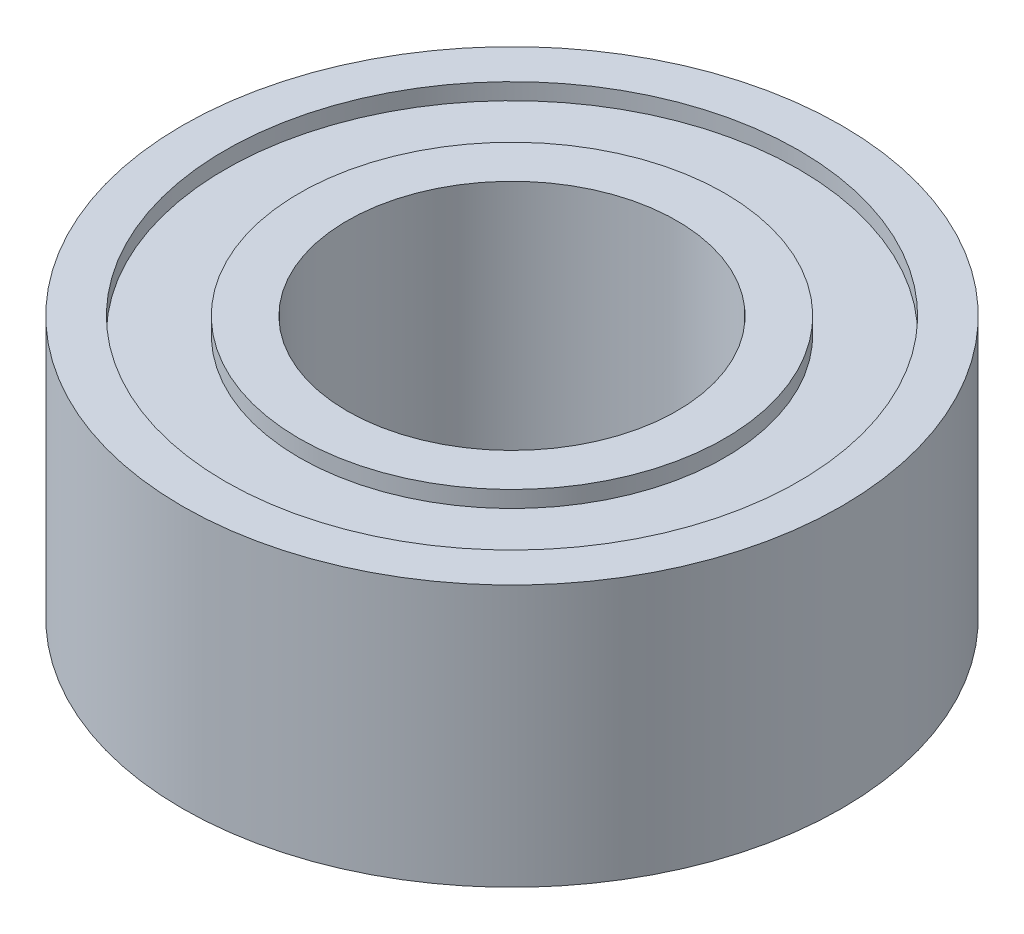
from build123d import *

# Parameters (mm, degrees)
SKETCH1_R           = 5
SKETCH1_R_2         = 2.5
BOSS_EXTRUDE1_DEPTH = 3.97
SKETCH2_R           = 4.35
SKETCH2_R_2         = 3.225
CUT_EXTRUDE1_DEPTH  = 0.25
SKETCH3_R           = 4.35
SKETCH3_R_2         = 3.225
CUT_EXTRUDE2_DEPTH  = 0.25


with BuildPart() as part:
    # Sketch1 → Boss-Extrude1 (new body)
    with BuildSketch(Plane(origin=(0, 0, 0), x_dir=(1, 0, 0), z_dir=(0, 1, 0))):
        Circle(SKETCH1_R)
        Circle(SKETCH1_R_2, mode=Mode.SUBTRACT)
    extrude(amount=BOSS_EXTRUDE1_DEPTH)

    # Sketch2 → Cut-Extrude1 (cut)
    with BuildSketch(Plane(origin=(0, 3.97, 0), x_dir=(1, 0, 0), z_dir=(0, 1, 0))):
        Circle(SKETCH2_R)
        Circle(SKETCH2_R_2, mode=Mode.SUBTRACT)
    extrude(amount=-CUT_EXTRUDE1_DEPTH, mode=Mode.SUBTRACT)

    # Sketch3 → Cut-Extrude2 (cut)
    with BuildSketch(Plane.XZ):
        Circle(SKETCH3_R)
        Circle(SKETCH3_R_2, mode=Mode.SUBTRACT)
    extrude(amount=-CUT_EXTRUDE2_DEPTH, mode=Mode.SUBTRACT)


solid = part.part
